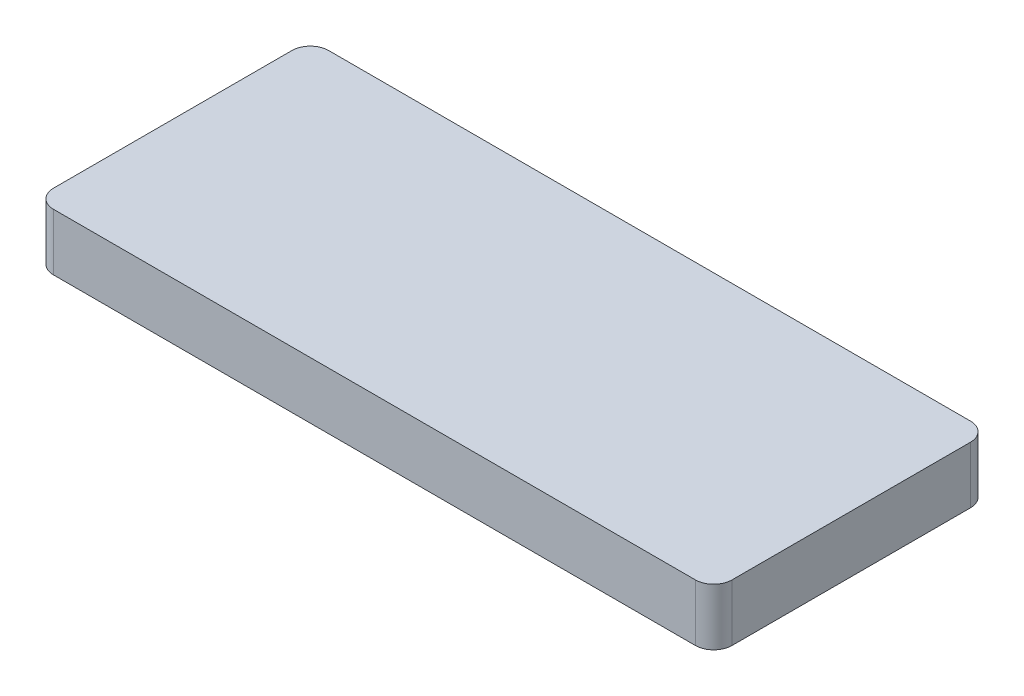
from build123d import *

# Parameters (mm, degrees)
BOSS_EXTRUDE1_DEPTH = 3.1


with BuildPart() as part:
    # Sketch1 → Boss-Extrude1 (new body)
    with BuildSketch(Plane(origin=(0, 0, 0), x_dir=(1, 0, 0), z_dir=(0, 1, 0))):
        with BuildLine():
            Line((-17.5, -7.5), (17.5, -7.5))
            ThreePointArc((17.5, -7.5), (18.207106781, -7.207106781), (18.5, -6.5))
            Line((18.5, -6.5), (18.5, 6.5))
            ThreePointArc((18.5, 6.5), (18.207106781, 7.207106781), (17.5, 7.5))
            Line((17.5, 7.5), (-17.5, 7.5))
            ThreePointArc((-17.5, 7.5), (-18.207106781, 7.207106781), (-18.5, 6.5))
            Line((-18.5, 6.5), (-18.5, -6.5))
            ThreePointArc((-18.5, -6.5), (-18.207106781, -7.207106781), (-17.5, -7.5))
        make_face()
    extrude(amount=BOSS_EXTRUDE1_DEPTH)


solid = part.part
